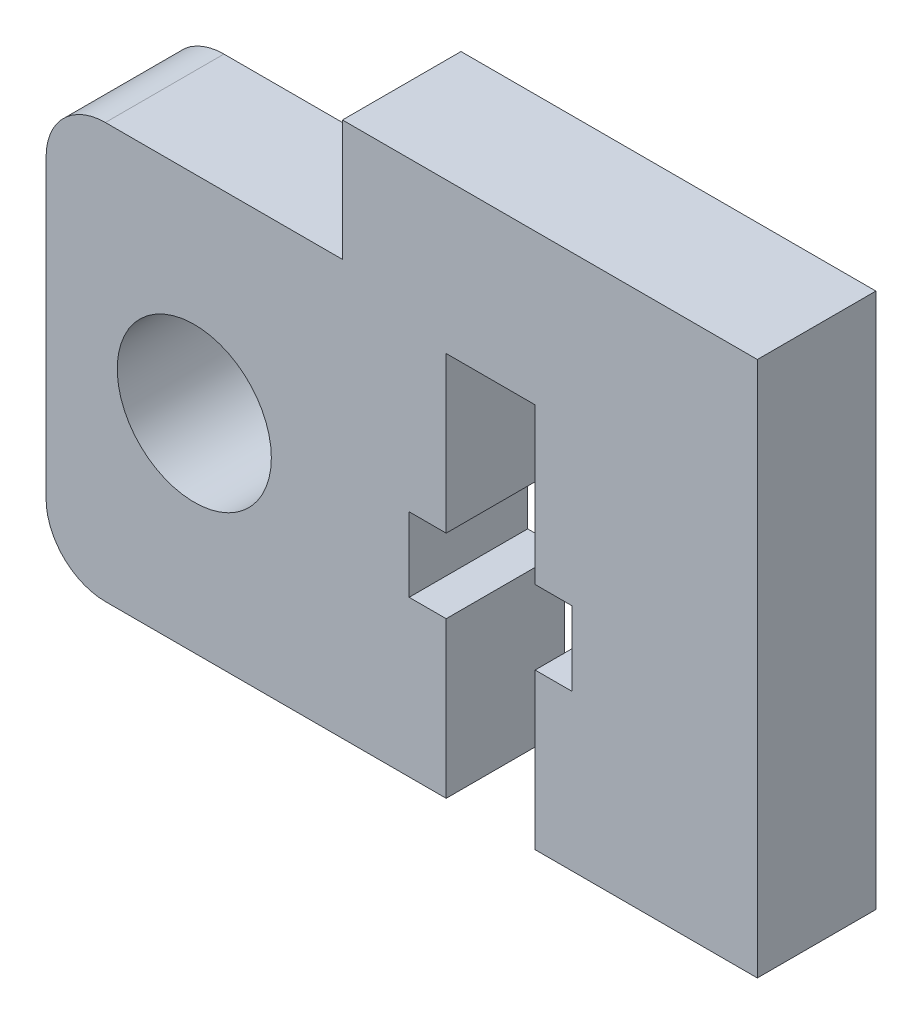
from build123d import *

# Parameters (mm, degrees)
EXTRUDE_1_DEPTH     = 4
SKETCH_2_R          = 2.6
CUT_EXTRUDE_1_DEPTH = 10


with BuildPart() as part:
    # Эскиз1 → Бобышка-Вытянуть1 (new body)
    with BuildSketch(Plane.XY):
        with BuildLine():
            Line((14, 0), (14, 18.074674191))
            Line((14, 18.074674191), (5, 18.074674191))
            Line((5, 18.074674191), (0, 18.074674191))
            Line((0, 18.074674191), (0, 14))
            Line((0, 14), (-8, 14))
            ThreePointArc((-8, 14), (-9.414213562, 13.414213562), (-10, 12))
            Line((-10, 12), (-10, 2))
            ThreePointArc((-10, 2), (-9.414213562, 0.585786438), (-8, 0))
            Line((-8, 0), (0, 0))
            Line((0, 0), (3.5, 0))
            Line((3.5, 0), (3.5, 5.25))
            Line((3.5, 5.25), (2.25, 5.25))
            Line((2.25, 5.25), (2.25, 7.75))
            Line((2.25, 7.75), (3.5, 7.75))
            Line((3.5, 7.75), (3.5, 13))
            Line((3.5, 13), (6.5, 13))
            Line((6.5, 13), (6.5, 7.75))
            Line((6.5, 7.75), (7.75, 7.75))
            Line((7.75, 7.75), (7.75, 5.25))
            Line((7.75, 5.25), (6.5, 5.25))
            Line((6.5, 5.25), (6.5, 0))
            Line((6.5, 0), (14, 0))
        make_face()
    extrude(amount=EXTRUDE_1_DEPTH)

    # Эскиз2 → Вырез-Вытянуть1 (cut)
    with BuildSketch(Plane.XY.offset(4)):
        with Locations((-5, 7)):
            Circle(SKETCH_2_R)
    extrude(amount=-CUT_EXTRUDE_1_DEPTH, mode=Mode.SUBTRACT)


solid = part.part
